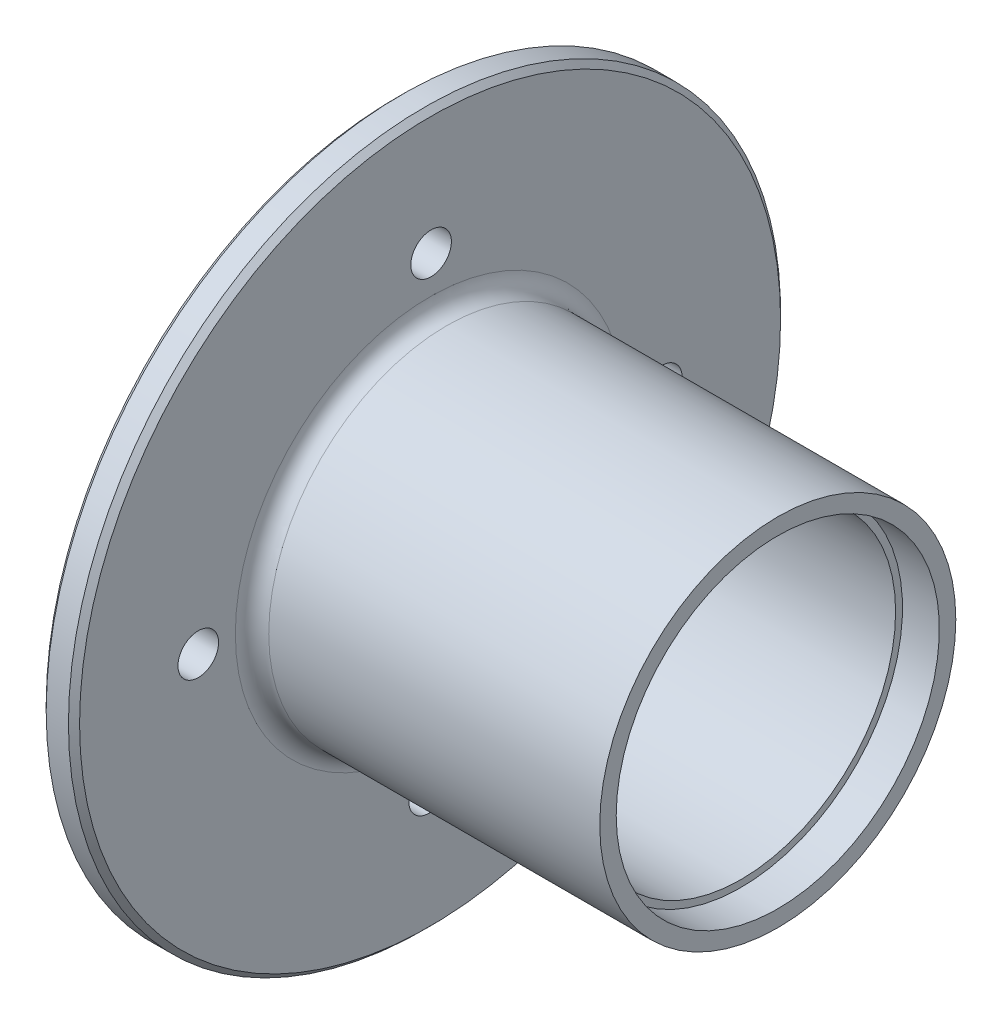
from build123d import *

# Parameters (mm, degrees)
F_12_CLEARANCE_HOLE1_D = 5.7912
CIRPATTERN1_COUNT      = 4


with BuildPart() as part:
    # Sketch1 → Revolve1 (revolve)
    with BuildSketch(Plane.XY):
        with BuildLine():
            Line((4.7625, 12.547042688), (4.7625, 17.143351136))
            Line((4.7625, 17.143351136), (20.20283565, 17.143351136))
            Line((20.20283565, 17.143351136), (20.20283565, 22.067968078))
            Line((20.20283565, 22.067968078), (49.112399892, 22.067968078))
            Line((49.112399892, 22.067968078), (49.112399892, 23.05289127))
            Line((49.112399892, 23.05289127), (54.368684681, 23.05289127))
            Line((54.368684681, 23.05289127), (54.368684681, 25.4))
            Line((54.368684681, 25.4), (7.14375, 25.4))
            ThreePointArc((7.14375, 25.4), (5.459951977, 26.097451977), (4.7625, 27.78125))
            Line((4.7625, 27.78125), (4.7625, 50.00625))
            Line((4.7625, 50.00625), (3.96875, 50.8))
            Line((3.96875, 50.8), (0.79375, 50.8))
            Line((0.79375, 50.8), (0, 50.00625))
            Line((0, 50.00625), (0, 17.143351136))
            Line((0, 17.143351136), (4.7625, 12.547042688))
        make_face()
    revolve(axis=Axis((207.498884421, 0, 0), (1, 0, 0)))

    # 12 Clearance Hole1 (through all)
    with Locations(Plane(origin=(0, 33.069002249, -0.146973343), x_dir=(0, 0, -1), z_dir=(-1, 0, 0))):
        with Locations((0, 0)):
            f_12_clearance_hole1 = Hole(F_12_CLEARANCE_HOLE1_D / 2)

    # CirPattern1: 12 Clearance Hole1 ×4 about axis
    cirpattern1_axis = Axis((0, 0, 0), (1, 0, 0))
    for i in range(1, CIRPATTERN1_COUNT):
        add(f_12_clearance_hole1.rotate(cirpattern1_axis, i * 360 / CIRPATTERN1_COUNT), mode=Mode.SUBTRACT)


solid = part.part
